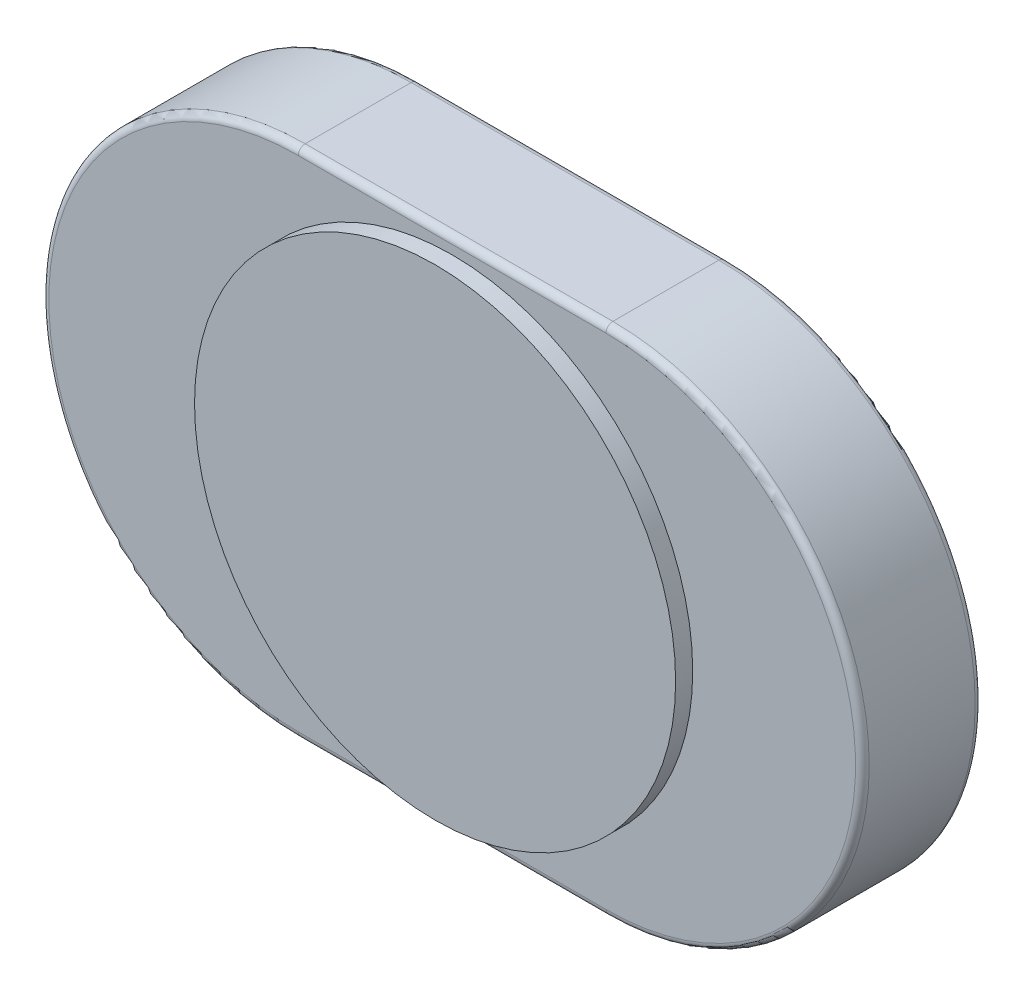
from build123d import *

# Parameters (mm, degrees)
BOSS_EXTRUDE1_DEPTH = 3.5
SKETCH2_R           = 7.036998645
BOSS_EXTRUDE2_DEPTH = 0.5
FILLET1_R           = 0.2


with BuildPart() as part:
    # Sketch1 → Boss-Extrude1 (new body)
    with BuildSketch(Plane.XY):
        with BuildLine():
            Line((-4.5, -7.5), (4.5, -7.5))
            ThreePointArc((4.5, -7.5), (12, 0), (4.5, 7.5))
            Line((4.5, 7.5), (-4.5, 7.5))
            ThreePointArc((-4.5, 7.5), (-12, 0), (-4.5, -7.5))
        make_face()
    extrude(amount=BOSS_EXTRUDE1_DEPTH)

    # Sketch2 → Boss-Extrude2 (add)
    with BuildSketch(Plane.XY.offset(3.5)):
        Circle(SKETCH2_R)
    extrude(amount=BOSS_EXTRUDE2_DEPTH)

    # Fillet1
    fillet1_edges = [part.edges().sort_by_distance(p)[0] for p in [
        (-12, 0, 3.5),
        (0, -7.5, 3.5),
        (12, 0, 3.5),
        (0, -7.5, 0),
        (-12, 0, 0),
        (0, 7.5, 0),
        (12, 0, 0),
        (0, 7.5, 3.5),
    ]]
    fillet(fillet1_edges, radius=FILLET1_R)


solid = part.part
